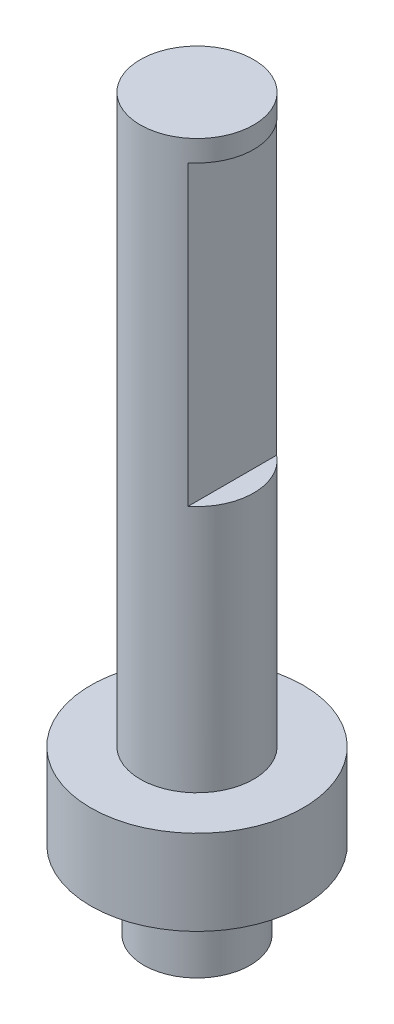
from build123d import *

# Parameters (mm, degrees)
SKETCH1_R           = 7.5
BOSS_EXTRUDE1_DEPTH = 11
SKETCH2_R           = 15
BOSS_EXTRUDE2_DEPTH = 12
SKETCH3_R           = 8
BOSS_EXTRUDE3_DEPTH = 80
SKETCH4_W           = 9.801818504
SKETCH4_H           = 42
CUT_EXTRUDE1_DEPTH  = 40


with BuildPart() as part:
    # Sketch1 → Boss-Extrude1 (new body)
    with BuildSketch(Plane(origin=(0, 0, 0), x_dir=(1, 0, 0), z_dir=(0, 1, 0))):
        Circle(SKETCH1_R)
    extrude(amount=-BOSS_EXTRUDE1_DEPTH)

    # Sketch2 → Boss-Extrude2 (add)
    with BuildSketch(Plane(origin=(0, 0, 0), x_dir=(1, 0, 0), z_dir=(0, 1, 0))):
        Circle(SKETCH2_R)
    extrude(amount=BOSS_EXTRUDE2_DEPTH)

    # Sketch3 → Boss-Extrude3 (add)
    with BuildSketch(Plane(origin=(0, 12, 0), x_dir=(1, 0, 0), z_dir=(0, 1, 0))):
        Circle(SKETCH3_R)
    extrude(amount=BOSS_EXTRUDE3_DEPTH)

    # Sketch4 → Cut-Extrude1 (cut, symmetric)
    with BuildSketch(Plane.XY):
        with Locations((9.900909252, 68)):
            Rectangle(SKETCH4_W, SKETCH4_H)
    extrude(amount=CUT_EXTRUDE1_DEPTH, both=True, mode=Mode.SUBTRACT)


solid = part.part
